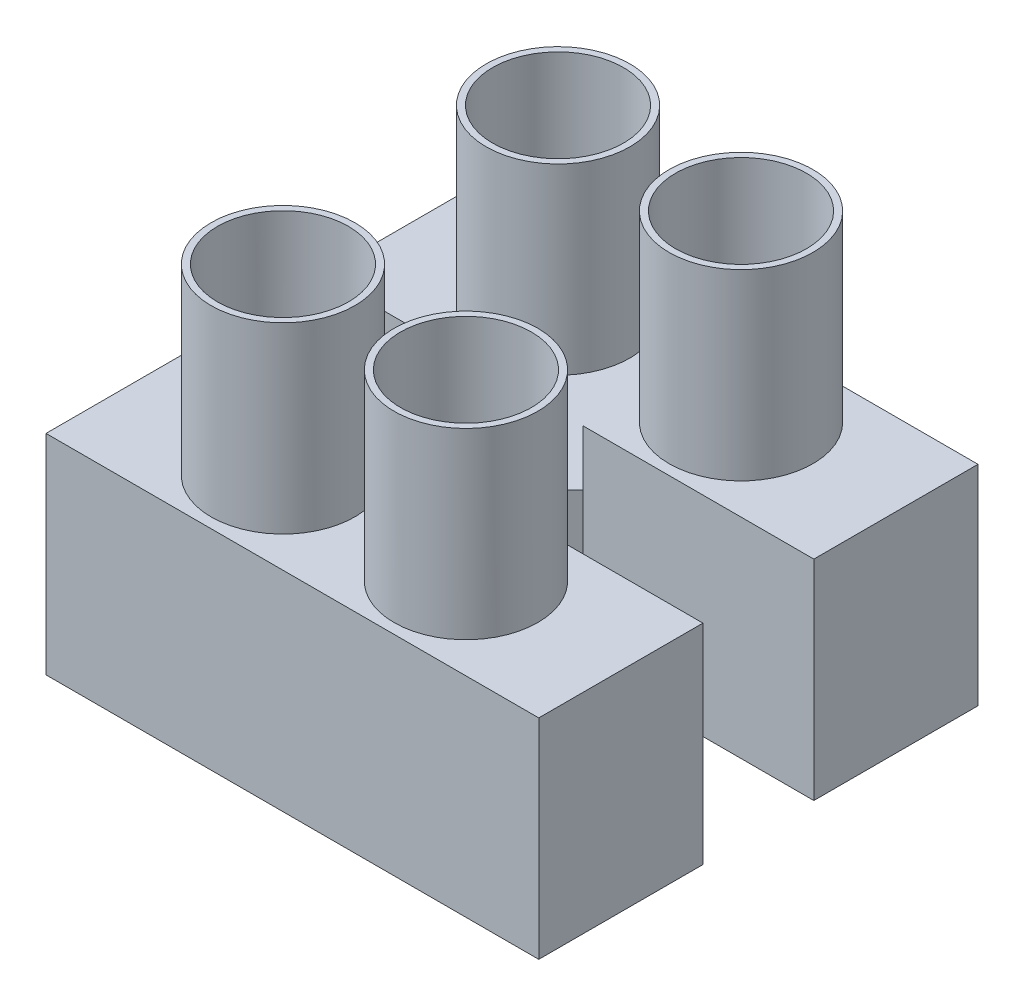
from build123d import *

# Parameters (mm, degrees)
SKETCH1_W                 = 18.85
SKETCH1_H                 = 6.28
BOSS_EXTRUDE1_DEPTH       = 8
BOSS_EXTRUDE2_DEPTH       = 8
BOSS_EXTRUDE3_DEPTH       = 8
SKETCH2_R                 = 2.75
SKETCH2_R_2               = 2.505012867
BOSS_EXTRUDE5_DEPTH       = 15
MIRROR2_COPY_1_SKETCH_R   = 2.75
MIRROR2_COPY_1_SKETCH_R_2 = 2.505012867
MIRROR2_COPY_1_DEPTH      = 15


with BuildPart() as part:
    # Sketch1 → Boss-Extrude1 (new body)
    with BuildSketch(Plane(origin=(0, 0, 0), x_dir=(1, 0, 0), z_dir=(0, 1, 0))):
        with Locations((-0.25472973, 1.292297297)):
            Rectangle(SKETCH1_W, SKETCH1_H)
    extrude(amount=BOSS_EXTRUDE1_DEPTH)



with BuildPart() as body_2:
    # Sketch1_3 → Boss-Extrude2 (new body)
    with BuildSketch(Plane(origin=(0, 0, 0), x_dir=(1, 0, 0), z_dir=(0, 1, 0))):
        Polygon((-0.85472973, 8.674937984), (-0.25472973, 8.674937984), (0.34527027, 8.674937984), (9.17027027, 8.674937984), (9.17027027, 14.954937984), (-9.67972973, 14.954937984), (-9.67972973, 8.674937984), align=None)
    extrude(amount=BOSS_EXTRUDE2_DEPTH)


with BuildPart() as part_1:
    add(part.part)

    add(body_2.part)  # Boss-Extrude3 merges body 2
    # Sketch1_5 → Boss-Extrude3 (add)
    with BuildSketch(Plane(origin=(0, 0, 0), x_dir=(1, 0, 0), z_dir=(0, 1, 0))):
        Polygon((1.866590614, 6.553617641), (-0.25472973, 4.432297297), (0.34527027, 4.432297297), (2.466590614, 6.553617641), (0.34527027, 8.674937984), (-0.25472973, 8.674937984), align=None)
        Polygon((-0.85472973, 4.432297297), (-0.25472973, 4.432297297), (-2.376050073, 6.553617641), (-0.25472973, 8.674937984), (-0.85472973, 8.674937984), (-2.976050073, 6.553617641), align=None)
    extrude(amount=BOSS_EXTRUDE3_DEPTH)

    # Sketch2 → Boss-Extrude5 (add)
    with BuildSketch(Plane(origin=(0, 0, 0), x_dir=(1, 0, 0), z_dir=(0, 1, 0))):
        with Locations((3.24527027, 11.814937984)):
            Circle(SKETCH2_R)
        with Locations((3.24527027, 11.814937984)):
            Circle(SKETCH2_R_2, mode=Mode.SUBTRACT)
    boss_extrude5 = extrude(amount=BOSS_EXTRUDE5_DEPTH)

    # Mirror1: Boss-Extrude5 across plane
    add(boss_extrude5.mirror(Plane(origin=(-0.25472973, 0, 0), x_dir=(0, 0, 1), z_dir=(1, 0, 0))))

    # Mirror2: Boss-Extrude5 across plane
    add(boss_extrude5.mirror(Plane(origin=(0, 0, -6.553617641), x_dir=(1, 0, 0), z_dir=(0, 0, -1))))

    # Mirror2 copy 1 sketch → Mirror2 copy 1 (add)
    with BuildSketch(Plane(origin=(-0.509459459, 0, -13.107235282), x_dir=(-1, 0, 0), z_dir=(0, 1, 0))):
        with Locations((3.24527027, 11.814937984)):
            Circle(MIRROR2_COPY_1_SKETCH_R)
        with Locations((3.24527027, 11.814937984)):
            Circle(MIRROR2_COPY_1_SKETCH_R_2, mode=Mode.SUBTRACT)
    extrude(amount=MIRROR2_COPY_1_DEPTH)


solid = part_1.part
